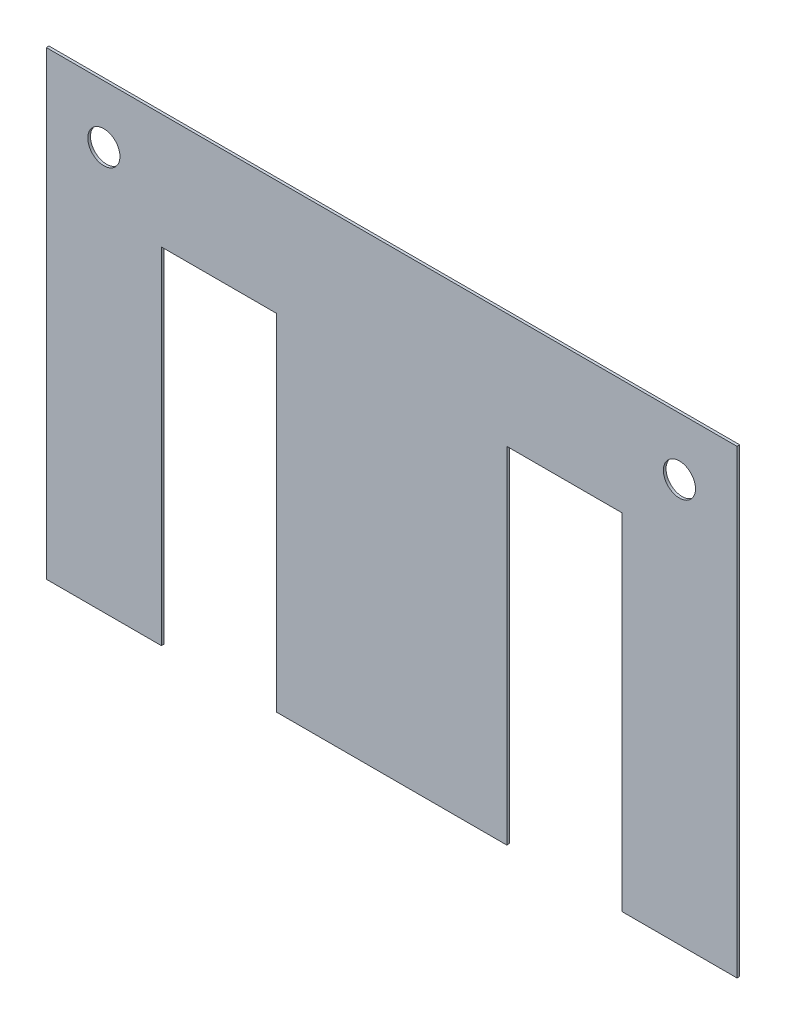
from build123d import *

# Parameters (mm, degrees)
SKETCH1_R           = 3
BOSS_EXTRUDE1_DEPTH = 0.5


with BuildPart() as part:
    # Sketch1 → Boss-Extrude1 (new body)
    with BuildSketch(Plane.XY):
        Polygon((0, 0), (0, 86), (129, 86), (129, 0), (107.5, 0), (107.5, 64.5), (86, 64.5), (86, 0), (43, 0), (43, 64.5), (21.5, 64.5), (21.5, 0), align=None)
        with Locations((10.75, 75.25)):
            Circle(SKETCH1_R, mode=Mode.SUBTRACT)
        with Locations((118.25, 75.25)):
            Circle(SKETCH1_R, mode=Mode.SUBTRACT)
    extrude(amount=BOSS_EXTRUDE1_DEPTH)


solid = part.part
